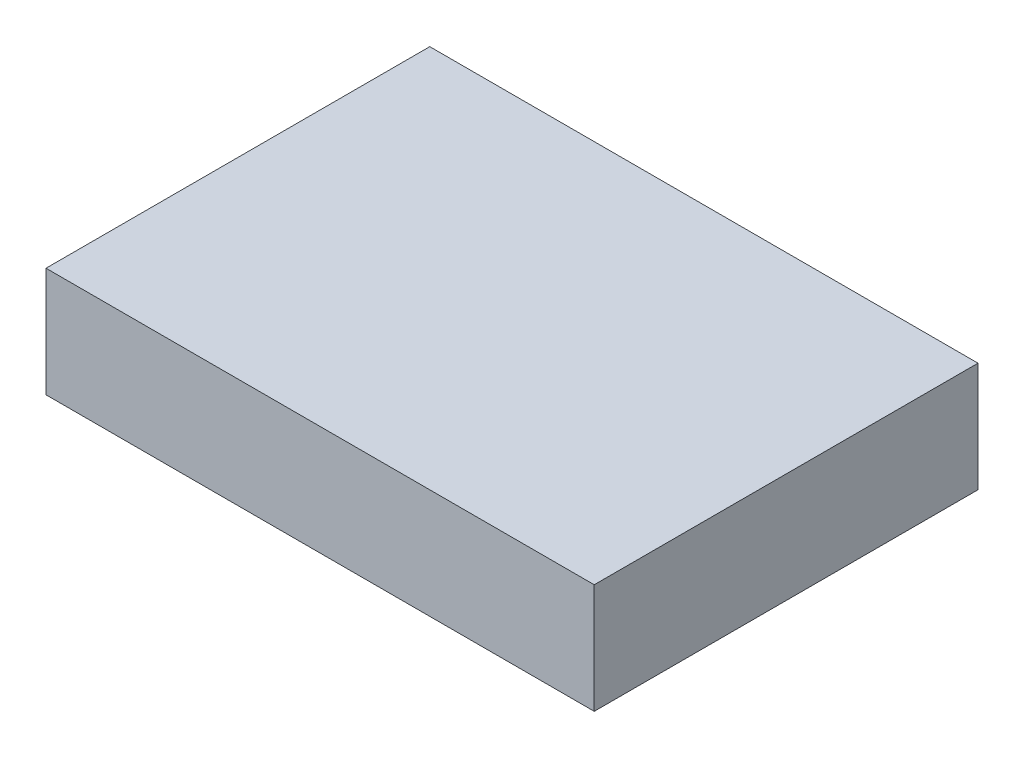
from build123d import *

# Parameters (mm, degrees)
SKETCH2_W           = 50
SKETCH2_H           = 35
BOSS_EXTRUDE2_DEPTH = 10


with BuildPart() as part:
    # Sketch2 → Boss-Extrude2 (new body)
    with BuildSketch(Plane(origin=(0, 0, 0), x_dir=(1, 0, 0), z_dir=(0, 1, 0))):
        with Locations((-5.789473684, -8.201754386)):
            Rectangle(SKETCH2_W, SKETCH2_H)
    extrude(amount=BOSS_EXTRUDE2_DEPTH)


solid = part.part
